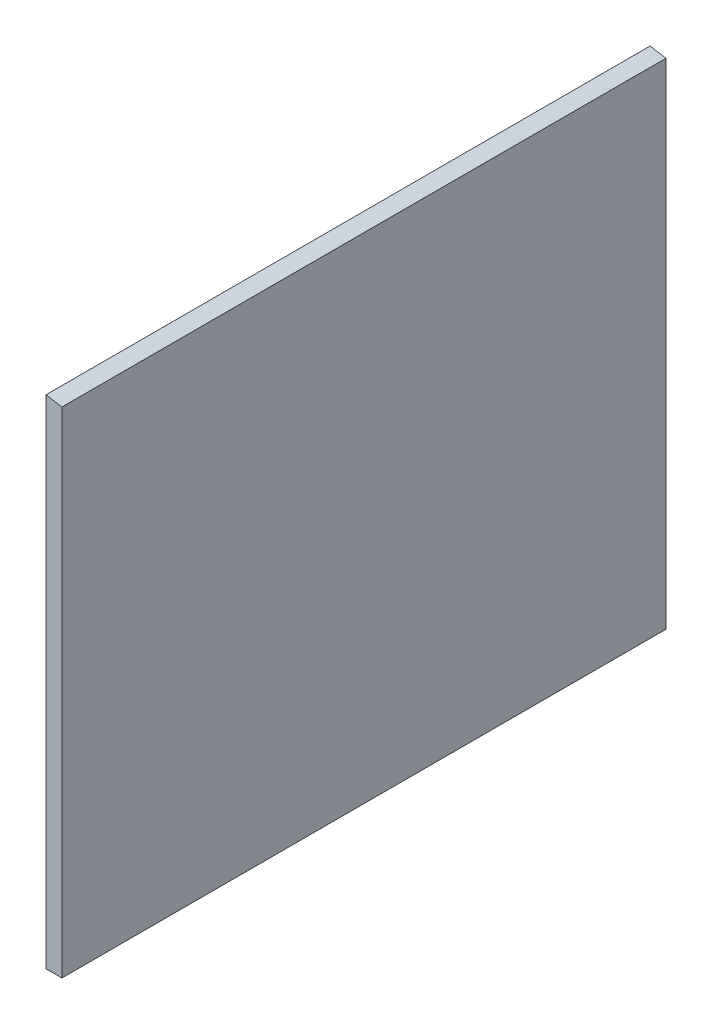
from build123d import *

# Parameters (mm, degrees)
BOSS_EXTRUDE1_DEPTH = 57.094


with BuildPart() as part:
    # Sketch1 → Boss-Extrude1 (new body, symmetric)
    with BuildSketch(Plane.XY):
        Polygon((0, 0), (0, 93.98), (3, 93.470433416), (3, 0), align=None)
    extrude(amount=BOSS_EXTRUDE1_DEPTH, both=True)


solid = part.part
